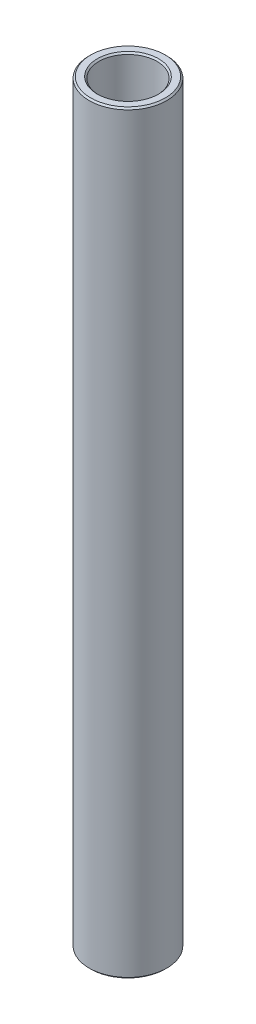
from build123d import *

# Parameters (mm, degrees)
SKETCH1_W     = 1.5875
SKETCH1_H     = 123.43257
CHAMFER1_SIZE = 0.254


with BuildPart() as part:
    # Sketch1 → Revolve1 (revolve)
    with BuildSketch(Plane.XY):
        with Locations((5.55625, 0)):
            Rectangle(SKETCH1_W, SKETCH1_H)
    revolve(axis=Axis((0, 11.60859375, 0), (0, -1, 0)))

    # Chamfer1
    chamfer1_edges = [part.edges().sort_by_distance(p)[0] for p in [
        (-4.7625, -61.716285, 0),
        (-6.35, -61.716285, 0),
        (-6.35, 61.716285, 0),
        (-4.7625, 61.716285, 0),
    ]]
    chamfer(chamfer1_edges, length=CHAMFER1_SIZE)


solid = part.part
